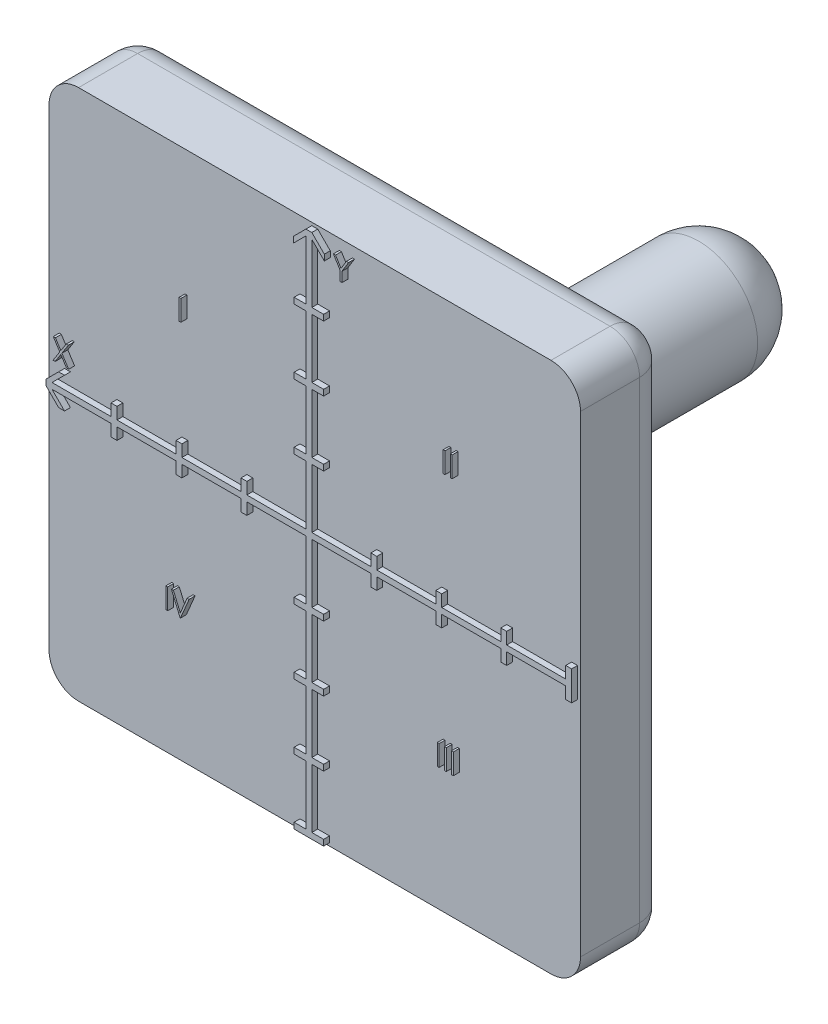
from build123d import *

# Parameters (mm, degrees)
CROQUIS1_W               = 90
CROQUIS1_H               = 90
SALIENTE_EXTRUIR2_DEPTH  = 15
CROQUIS2_R               = 10
SALIENTE_EXTRUIR3_DEPTH  = 60
SALIENTE_EXTRUIR4_DEPTH  = 1
REDONDEO1_R              = 5
REDONDEO2_R              = 5
REDONDEO3_R              = 5
REDONDEO4_R              = 10
CORTAR_EXTRUIR3_DEPTH    = 7
CROQUIS7_W               = 2
CROQUIS7_H               = 1
CROQUIS7_W_2             = 1
CROQUIS7_H_2             = 2
SALIENTE_EXTRUIR7_DEPTH  = 1
SALIENTE_EXTRUIR8_DEPTH  = 1
CROQUIS8_W               = 0.314102564
CROQUIS8_H               = 3.5
SALIENTE_EXTRUIR10_DEPTH = 1


with BuildPart() as part:
    # Croquis1 → Saliente-Extruir2 (new body)
    with BuildSketch(Plane.XY):
        Rectangle(CROQUIS1_W, CROQUIS1_H)
    extrude(amount=SALIENTE_EXTRUIR2_DEPTH)

    # Croquis2 → Saliente-Extruir3 (add)
    with BuildSketch(Plane(origin=(0, 0, 0), x_dir=(-1, 0, 0), z_dir=(0, 0, -1))):
        Circle(CROQUIS2_R)
    extrude(amount=SALIENTE_EXTRUIR3_DEPTH)

    # Croquis3 → Saliente-Extruir4 (add)
    with BuildSketch(Plane.XY.offset(15)):
        Polygon((10.5, 0.5), (10.5, 2.5), (11.5, 2.5), (11.5, 0.5), (21.5, 0.5), (21.5, 2.5), (22.5, 2.5), (22.5, 0.5), (32.5, 0.5), (32.5, 2.5), (33.5, 2.5), (33.5, 0.5), (43.5, 0.5), (41.378679656, 2.621320344), (42.378679656, 2.621320344), (44.5, 0.5), (44.5, -0.5), (42.378679656, -2.621320344), (41.378679656, -2.621320344), (43.5, -0.5), (33.5, -0.5), (33.5, -2.5), (32.5, -2.5), (32.5, -0.5), (22.5, -0.5), (22.5, -2.5), (21.5, -2.5), (21.5, -0.5), (11.5, -0.5), (11.5, -2.5), (10.5, -2.5), (10.5, -0.5), (0.5, -0.5), (0.5, -10.5), (2.5, -10.5), (2.5, -11.5), (0.5, -11.5), (0.5, -21.5), (2.5, -21.5), (2.5, -22.5), (0.5, -22.5), (0.5, -32.5), (2.5, -32.5), (2.5, -33.5), (0.5, -33.5), (0.5, -43.5), (2.621320344, -41.378679656), (2.621320344, -42.378679656), (0.5, -44.5), (-0.5, -44.5), (-2.621320344, -42.378679656), (-2.621320344, -41.378679656), (-0.5, -43.5), (-0.5, -33.5), (-2.5, -33.5), (-2.5, -32.5), (-0.5, -32.5), (-0.5, -22.5), (-2.5, -22.5), (-2.5, -21.5), (-0.5, -21.5), (-0.5, -11.5), (-2.5, -11.5), (-2.5, -10.5), (-0.5, -10.5), (-0.5, -0.5), (-10.5, -0.5), (-10.5, -2.5), (-11.5, -2.5), (-11.5, -0.5), (-21.5, -0.5), (-21.5, -2.5), (-22.5, -2.5), (-22.5, -0.5), (-32.5, -0.5), (-32.5, -2.5), (-33.5, -2.5), (-33.5, -0.5), (-43.5, -0.5), (-41.378679656, -2.621320344), (-42.378679656, -2.621320344), (-44.5, -0.5), (-44.5, 0.5), (-42.378679656, 2.621320344), (-41.378679656, 2.621320344), (-43.5, 0.5), (-33.5, 0.5), (-33.5, 2.5), (-32.5, 2.5), (-32.5, 0.5), (-22.5, 0.5), (-22.5, 2.5), (-21.5, 2.5), (-21.5, 0.5), (-11.5, 0.5), (-11.5, 2.5), (-10.5, 2.5), (-10.5, 0.5), (-0.5, 0.5), (-0.5, 10.5), (-2.5, 10.5), (-2.5, 11.5), (-0.5, 11.5), (-0.5, 21.5), (-2.5, 21.5), (-2.5, 22.5), (-0.5, 22.5), (-0.5, 32.5), (-2.5, 32.5), (-2.5, 33.5), (-0.5, 33.5), (-0.5, 43.5), (-2.621320344, 41.378679656), (-2.621320344, 42.378679656), (-0.5, 44.5), (0.5, 44.5), (2.621320344, 42.378679656), (2.621320344, 41.378679656), (0.5, 43.5), (0.5, 33.5), (2.5, 33.5), (2.5, 32.5), (0.5, 32.5), (0.5, 22.5), (2.5, 22.5), (2.5, 21.5), (0.5, 21.5), (0.5, 11.5), (2.5, 11.5), (2.5, 10.5), (0.5, 10.5), (0.5, 0.5), align=None)
    extrude(amount=SALIENTE_EXTRUIR4_DEPTH)

    # Redondeo1
    redondeo1_edges = [part.edges().sort_by_distance(p)[0] for p in [
        (45, -45, 7.5),
        (-45, -45, 7.5),
        (-45, 45, 7.5),
        (45, 45, 7.5),
    ]]
    fillet(redondeo1_edges, radius=REDONDEO1_R)

    # Redondeo2
    redondeo2_edges = [part.edges().sort_by_distance(p)[0] for p in [
        (0, -45, 0),
        (45, 0, 0),
        (-45, 0, 0),
        (0, 45, 0),
        (43.535533906, 43.535533906, 0),
        (-43.535533906, 43.535533906, 0),
        (43.535533906, -43.535533906, 0),
        (-43.535533906, -43.535533906, 0),
    ]]
    fillet(redondeo2_edges, radius=REDONDEO2_R)

    # Redondeo3
    redondeo3_edges = [part.edges().sort_by_distance(p)[0] for p in [
        (10, 0, 0),
    ]]
    fillet(redondeo3_edges, radius=REDONDEO3_R)

    # Redondeo4
    redondeo4_edges = [part.edges().sort_by_distance(p)[0] for p in [
        (10, 0, -60),
    ]]
    fillet(redondeo4_edges, radius=REDONDEO4_R)

    # Croquis4 → Cortar-Extruir3 (cut)
    with BuildSketch(Plane.XY.offset(15)):
        Polygon((44.5, -0.5), (43.5, -0.5), (41.378679656, -2.621320344), (42.378679656, -2.621320344), align=None)
        Polygon((2.621320344, -41.378679656), (2.621320344, -42.378679656), (0.5, -44.5), (0.5, -43.5), align=None)
        Polygon((-0.5, -44.5), (-0.5, -43.5), (-2.621320344, -41.378679656), (-2.621320344, -42.378679656), align=None)
        Polygon((42.378679656, 2.621320344), (44.5, 0.5), (43.5, 0.5), (41.378679656, 2.621320344), align=None)
    extrude(amount=CORTAR_EXTRUIR3_DEPTH, mode=Mode.SUBTRACT)

    # Croquis7 → Saliente-Extruir7 (add)
    with BuildSketch(Plane.XY.offset(15)):
        with Locations((1.5, -44)):
            Rectangle(CROQUIS7_W, CROQUIS7_H)
        with Locations((-1.5, -44)):
            Rectangle(CROQUIS7_W, CROQUIS7_H)
        with Locations((44, 1.5)):
            Rectangle(CROQUIS7_W_2, CROQUIS7_H_2)
        with Locations((44, -1.5)):
            Rectangle(CROQUIS7_W_2, CROQUIS7_H_2)
    extrude(amount=SALIENTE_EXTRUIR7_DEPTH)

    # Croquis6 → Saliente-Extruir8 (add)
    with BuildSketch(Plane.XY.offset(15)):
        Polygon((-43.283137752, 7.349477316), (-42.920657784, 7.349477316), (-42.004291598, 5.917786611), (-41.087925412, 7.349477316), (-40.725445444, 7.349477316), (-41.822701053, 5.634533406), (-40.68057365, 3.849477316), (-41.043053618, 3.849477316), (-42.004291598, 5.351280201), (-42.965529579, 3.849477316), (-43.328009547, 3.849477316), (-42.185181021, 5.634533406), align=None)
        Polygon((4.161847677, 43.195141737), (4.521523158, 43.195141737), (5.441394953, 41.691235487), (6.359864504, 43.195141737), (6.719539985, 43.195141737), (5.597745113, 41.358903756), (5.597745113, 39.695141737), (5.283642549, 39.695141737), (5.283642549, 41.358903756), align=None)
    extrude(amount=SALIENTE_EXTRUIR8_DEPTH)

    # Croquis8 → Saliente-Extruir10 (add)
    with BuildSketch(Plane.XY.offset(15)):
        with Locations((-21.822729757, 21.999786624)):
            Rectangle(CROQUIS8_W, CROQUIS8_H)
        with Locations((22.888086812, 21.999786624)):
            Rectangle(CROQUIS8_W, CROQUIS8_H)
        with Locations((24.099625274, 21.999786624)):
            Rectangle(CROQUIS8_W, CROQUIS8_H)
        with Locations((21.898264065, -21.435024399)):
            Rectangle(CROQUIS8_W, CROQUIS8_H)
        with Locations((23.109802526, -21.435024399)):
            Rectangle(CROQUIS8_W, CROQUIS8_H)
        with Locations((24.321340988, -21.435024399)):
            Rectangle(CROQUIS8_W, CROQUIS8_H)
        with Locations((-24.064832005, -21.435024399)):
            Rectangle(CROQUIS8_W, CROQUIS8_H)
        Polygon((-23.279575594, -19.685024399), (-22.943037133, -19.685024399), (-21.776370466, -22.44323754), (-20.6097038, -19.685024399), (-20.273165338, -19.685024399), (-21.753934569, -23.185024399), (-21.798806364, -23.185024399), align=None)
    extrude(amount=SALIENTE_EXTRUIR10_DEPTH)


solid = part.part
